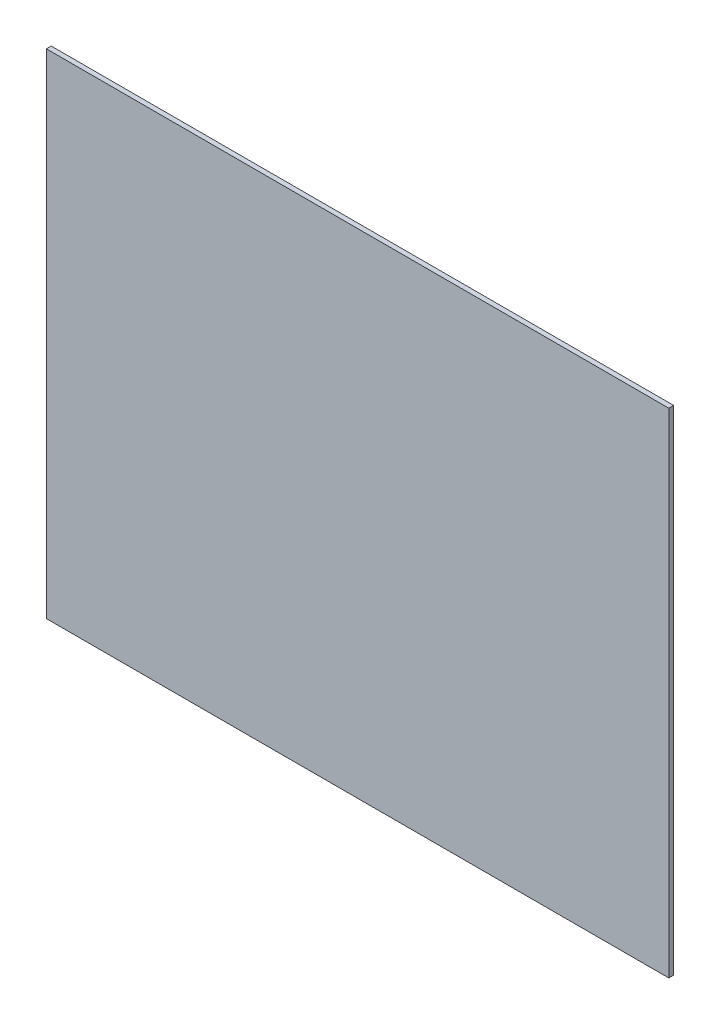
from build123d import *

# Parameters (mm, degrees)
SKETCH1_W           = 579
SKETCH1_H           = 459
BOSS_EXTRUDE1_DEPTH = 2.2479


with BuildPart() as part:
    # Sketch1 → Boss-Extrude1 (new body, symmetric)
    with BuildSketch(Plane.XY):
        Rectangle(SKETCH1_W, SKETCH1_H)
    extrude(amount=BOSS_EXTRUDE1_DEPTH, both=True)


solid = part.part
